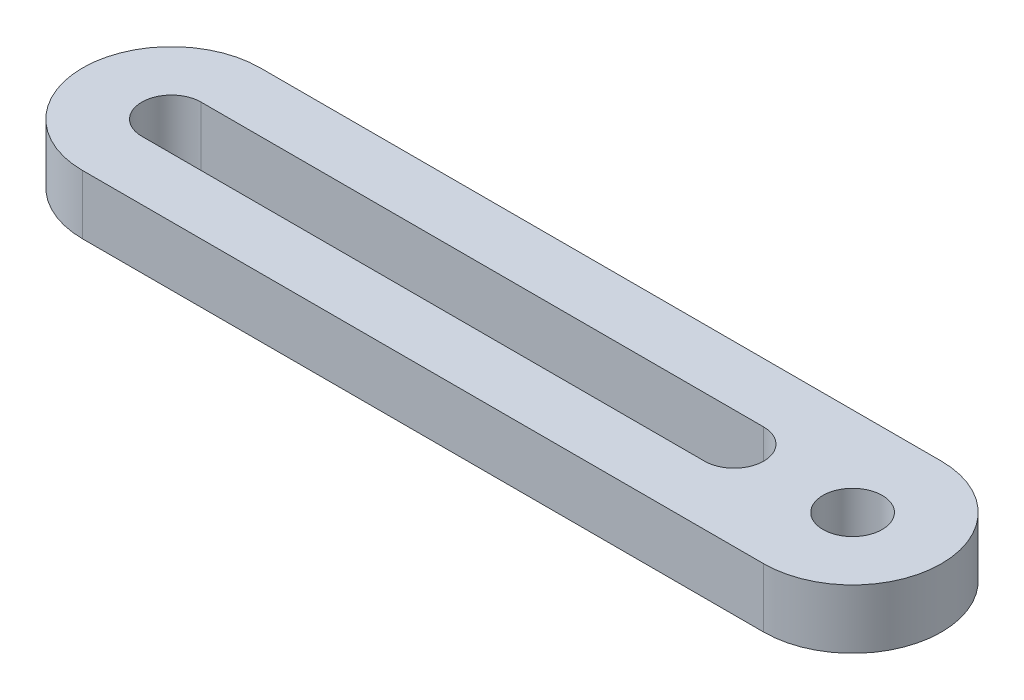
from build123d import *

# Parameters (mm, degrees)
SKETCH1_R           = 5
BOSS_EXTRUDE1_DEPTH = 10


with BuildPart() as part:
    # Sketch1 → Boss-Extrude1 (new body)
    with BuildSketch(Plane(origin=(0, 0, 0), x_dir=(1, 0, 0), z_dir=(0, 1, 0))):
        with BuildLine():
            Line((0, 15), (115, 15))
            ThreePointArc((115, 15), (130, 0), (115, -15))
            Line((115, -15), (0, -15))
            ThreePointArc((0, -15), (-15, 0), (0, 15))
        make_face()
        with Locations((115, 0)):
            Circle(SKETCH1_R, mode=Mode.SUBTRACT)
        with BuildLine():
            Line((0, 5), (95, 5))
            ThreePointArc((95, 5), (100, 0), (95, -5))
            Line((95, -5), (0, -5))
            ThreePointArc((0, -5), (-5, 0), (0, 5))
        make_face(mode=Mode.SUBTRACT)
    extrude(amount=BOSS_EXTRUDE1_DEPTH)


solid = part.part
